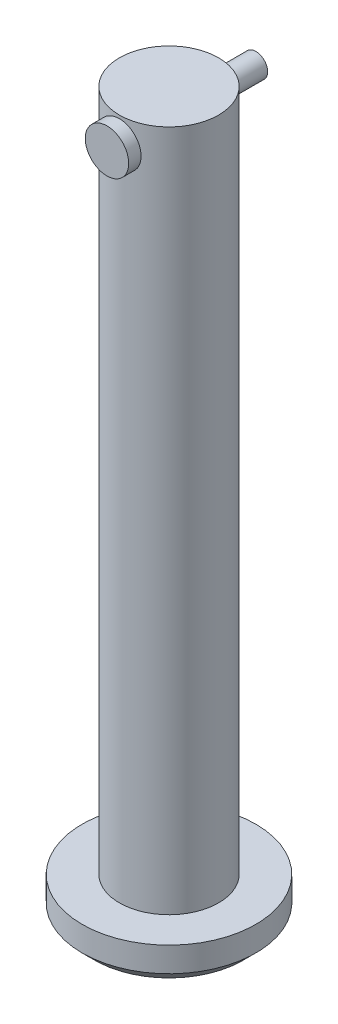
from build123d import *

# Parameters (mm, degrees)
SKETCH1_R                = 4
BOSS_EXTRUDE1_DEPTH      = 55
SKETCH2_R                = 7
BOSS_EXTRUDE2_DEPTH      = 3
CHAMFER1_SIZE            = 1
SKETCH3_R                = 1
CUT_EXTRUDE1_DEPTH       = 10
CUT_EXTRUDE1_DEPTH_BACK  = 10
SKETCH4_R                = 0.95
BOSS_EXTRUDE3_DEPTH      = 5
BOSS_EXTRUDE3_DEPTH_BACK = 7
SKETCH5_R                = 1.75
BOSS_EXTRUDE4_DEPTH      = 1


with BuildPart() as part:
    # Sketch1 → Boss-Extrude1 (new body)
    with BuildSketch(Plane(origin=(0, 0, 0), x_dir=(1, 0, 0), z_dir=(0, 1, 0))):
        Circle(SKETCH1_R)
    extrude(amount=BOSS_EXTRUDE1_DEPTH)

    # Sketch2 → Boss-Extrude2 (add)
    with BuildSketch(Plane.XZ):
        Circle(SKETCH2_R)
    extrude(amount=BOSS_EXTRUDE2_DEPTH)

    # Chamfer1
    chamfer1_edges = [part.edges().sort_by_distance(p)[0] for p in [
        (-7, -3, 0),
    ]]
    chamfer(chamfer1_edges, length=CHAMFER1_SIZE)

    # Sketch3 → Cut-Extrude1 (cut, two sides)
    with BuildSketch(Plane.XY) as cut_extrude1_sk:
        with Locations((0, 53)):
            Circle(SKETCH3_R)
    extrude(amount=CUT_EXTRUDE1_DEPTH, mode=Mode.SUBTRACT)
    extrude(cut_extrude1_sk.sketch, amount=-CUT_EXTRUDE1_DEPTH_BACK, mode=Mode.SUBTRACT)


with BuildPart() as body_2:
    # Sketch4 → Boss-Extrude3 (new body, two sides)
    with BuildSketch(Plane.XY) as boss_extrude3_sk:
        with Locations((0, 53)):
            Circle(SKETCH4_R)
    extrude(amount=BOSS_EXTRUDE3_DEPTH)
    extrude(boss_extrude3_sk.sketch, amount=-BOSS_EXTRUDE3_DEPTH_BACK)

    # Sketch5 → Boss-Extrude4 (add)
    with BuildSketch(Plane.XY.offset(5)):
        with Locations((0, 53)):
            Circle(SKETCH5_R)
    extrude(amount=-BOSS_EXTRUDE4_DEPTH)


solid = Compound([part.part, body_2.part])
